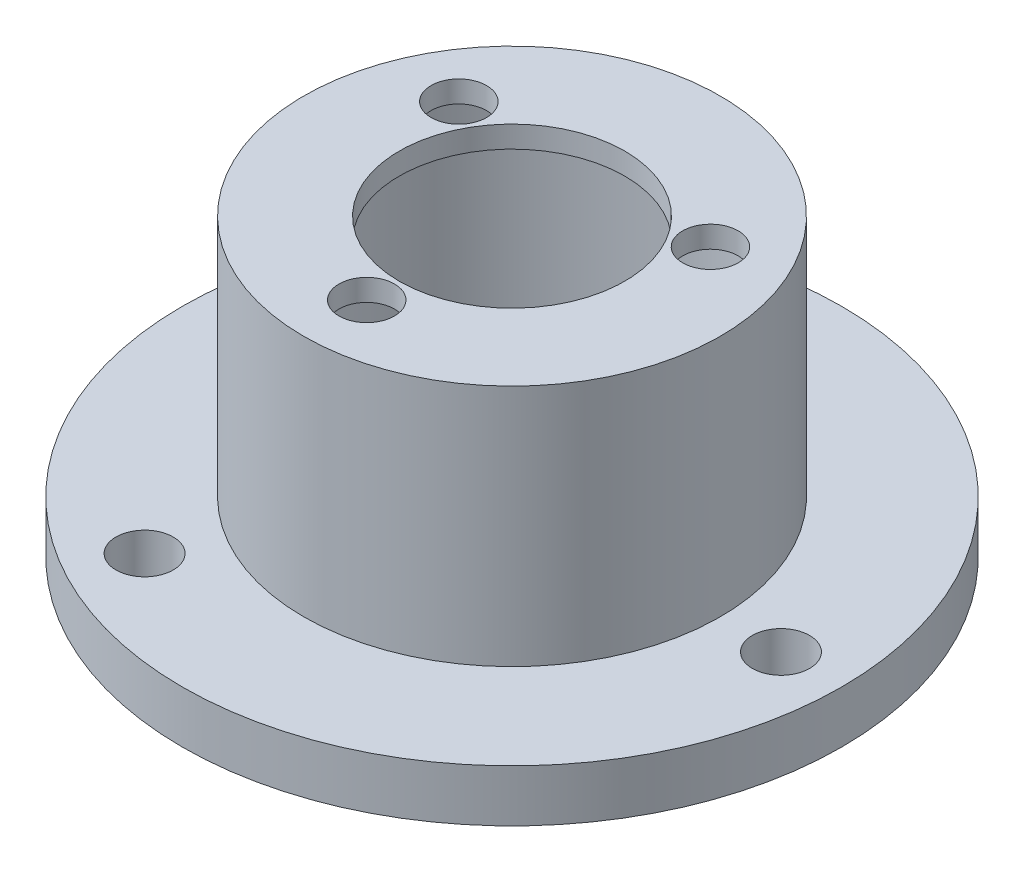
from build123d import *

# Parameters (mm, degrees)
SKETCH1_R                 = 19
SKETCH1_R_2               = 11
BOSS_EXTRUDE1_DEPTH       = 3
SKETCH2_R                 = 12
SKETCH2_R_2               = 11
BOSS_EXTRUDE2_DEPTH       = 14
SKETCH3_R                 = 12
SKETCH3_R_2               = 6.5
BOSS_EXTRUDE3_DEPTH       = 1.25
M3_CLEARANCE_HOLE1_D      = 3.2
M3_CLEARANCE_HOLE1_DEPTH  = 7.5
M3_CLEARANCE_HOLE1_TIP    = 0.96137699
M4X0_7_TAPPED_HOLE1_D     = 3.3
M4X0_7_TAPPED_HOLE1_DEPTH = 3


with BuildPart() as part:
    # Sketch1 → Boss-Extrude1 (new body)
    with BuildSketch(Plane(origin=(0, 0, 0), x_dir=(1, 0, 0), z_dir=(0, 1, 0))):
        Circle(SKETCH1_R)
        Circle(SKETCH1_R_2, mode=Mode.SUBTRACT)
    extrude(amount=BOSS_EXTRUDE1_DEPTH)

    # Sketch2 → Boss-Extrude2 (add)
    with BuildSketch(Plane(origin=(0, 3, 0), x_dir=(1, 0, 0), z_dir=(0, 1, 0))):
        Circle(SKETCH2_R)
        Circle(SKETCH2_R_2, mode=Mode.SUBTRACT)
    extrude(amount=BOSS_EXTRUDE2_DEPTH)

    # Sketch3 → Boss-Extrude3 (add)
    with BuildSketch(Plane(origin=(0, 17, 0), x_dir=(1, 0, 0), z_dir=(0, 1, 0))):
        Circle(SKETCH3_R)
        Circle(SKETCH3_R_2, mode=Mode.SUBTRACT)
    extrude(amount=-BOSS_EXTRUDE3_DEPTH)

    # M3 Clearance Hole1
    with Locations(Plane(origin=(0, 17, 0), x_dir=(1, 0, 0), z_dir=(0, 1, 0))):
        with Locations((-7.25, 4.185868355), (7.25, 4.185868355), (0, -8.3715)):
            Hole(M3_CLEARANCE_HOLE1_D / 2, depth=M3_CLEARANCE_HOLE1_DEPTH)
            with Locations((0, 0, -(M3_CLEARANCE_HOLE1_DEPTH + M3_CLEARANCE_HOLE1_TIP / 2))):  # 118° drill point
                Cone(0, M3_CLEARANCE_HOLE1_D / 2, M3_CLEARANCE_HOLE1_TIP, mode=Mode.SUBTRACT)

    # M4x0.7 Tapped Hole1
    with Locations(Plane(origin=(0, 3, 0), x_dir=(1, 0, 0), z_dir=(0, 1, 0))):
        with Locations((-7.75, 13.423393759), (-7.75, -13.423393759), (15.5, 0)):
            Hole(M4X0_7_TAPPED_HOLE1_D / 2, depth=M4X0_7_TAPPED_HOLE1_DEPTH)


solid = part.part
